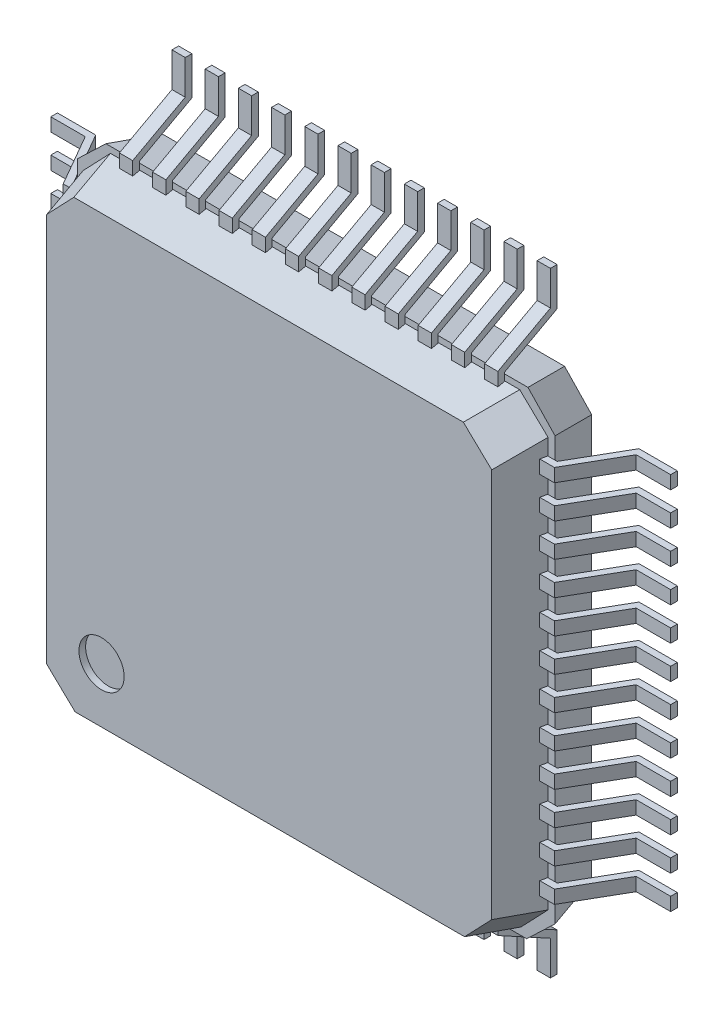
from build123d import *
from OCP.BRepFilletAPI import BRepFilletAPI_MakeChamfer

# Parameters (mm, degrees)
SKETCH1_W             = 7
SKETCH1_H             = 7
BOSS_EXTRUDE1_DEPTH   = 0.7
BOSS_EXTRUDE1_TAPER   = 12
CHAMFER1_SIZE         = 0.4
CHAMFER1_SIZE2        = 0.418480959
SKETCH2_W             = 7.192202475
SKETCH2_H             = 7.202004905
BOSS_EXTRUDE2_DEPTH   = 0.7
BOSS_EXTRUDE2_DRAFT   = -12
CHAMFER3_SIZE         = 0.4
CHAMFER3_SIZE2        = 0.418480959
EXTRUDE_THIN1_DEPTH   = 0.1
LPATTERN1_COUNT       = 7
LPATTERN1_PITCH       = 0.5
LPATTERN1_COL_COUNT   = 6
LPATTERN1_COL_PITCH   = 0.5
MIRROR2_COPY_1_DEPTH  = 0.1
MIRROR2_COPY_2_DEPTH  = 0.1
MIRROR2_COPY_3_DEPTH  = 0.1
MIRROR2_COPY_4_DEPTH  = 0.1
MIRROR2_COPY_5_DEPTH  = 0.1
MIRROR2_COPY_6_DEPTH  = 0.1
MIRROR2_COPY_7_DEPTH  = 0.1
MIRROR2_COPY_8_DEPTH  = 0.1
MIRROR2_COPY_9_DEPTH  = 0.1
MIRROR2_COPY_10_DEPTH = 0.1
MIRROR2_COPY_11_DEPTH = 0.1
EXTRUDE_THIN2_DEPTH   = 0.1
LPATTERN2_COUNT       = 7
LPATTERN2_PITCH       = 0.5
LPATTERN2_COL_COUNT   = 6
LPATTERN2_COL_PITCH   = 0.5
MIRROR3_COPY_1_DEPTH  = 0.1
MIRROR3_COPY_2_DEPTH  = 0.1
MIRROR3_COPY_3_DEPTH  = 0.1
MIRROR3_COPY_4_DEPTH  = 0.1
MIRROR3_COPY_5_DEPTH  = 0.1
MIRROR3_COPY_6_DEPTH  = 0.1
MIRROR3_COPY_7_DEPTH  = 0.1
MIRROR3_COPY_8_DEPTH  = 0.1
MIRROR3_COPY_9_DEPTH  = 0.1
MIRROR3_COPY_10_DEPTH = 0.1
MIRROR3_COPY_11_DEPTH = 0.1
SKETCH6_R             = 0.340417577
CUT_EXTRUDE2_DEPTH    = 0.1


with BuildPart() as part:
    # Sketch1 → Boss-Extrude1 (new body)
    with BuildSketch(Plane.XY):
        with Locations((3.5, 3.5)):
            Rectangle(SKETCH1_W, SKETCH1_H)
    extrude(amount=BOSS_EXTRUDE1_DEPTH, taper=BOSS_EXTRUDE1_TAPER)

    # Chamfer1: one chamfer whose edges measure the first distance from different faces: ONE call of the kernel's chamfer builder (chamfer() names one face for all edges)
    chamfer1_edges_1 = [part.edges().sort_by_distance(p)[0] for p in [
        (0.074394797, 6.925605203, 0.35),
    ]]
    chamfer1_side_1 = [part.faces().sort_by_distance(p)[0] for p in [
        (3.5, 6.926143754, 0.347466318),
    ]]
    chamfer1_edges_2 = [part.edges().sort_by_distance(p)[0] for p in [
        (6.925605203, 6.925605203, 0.35),
    ]]
    chamfer1_side_2 = [part.faces().sort_by_distance(p)[0] for p in [
        (6.926143754, 3.5, 0.347466318),
    ]]
    chamfer1_edges_3 = [part.edges().sort_by_distance(p)[0] for p in [
        (6.925605203, 0.074394797, 0.35),
    ]]
    chamfer1_side_3 = [part.faces().sort_by_distance(p)[0] for p in [
        (3.5, 0.073856246, 0.347466318),
    ]]
    chamfer1_edges_4 = [part.edges().sort_by_distance(p)[0] for p in [
        (0.074395259, 0.074395259, 0.350002173),
    ]]
    chamfer1_side_4 = [part.faces().sort_by_distance(p)[0] for p in [
        (0.073856246, 3.5, 0.347466318),
    ]]
    chamfer1 = BRepFilletAPI_MakeChamfer(part.part.solid().wrapped)
    for e in chamfer1_edges_1:
        chamfer1.Add(CHAMFER1_SIZE, CHAMFER1_SIZE2, e.wrapped, chamfer1_side_1[0].wrapped)  # the first distance lies on this face
    for e in chamfer1_edges_2:
        chamfer1.Add(CHAMFER1_SIZE, CHAMFER1_SIZE2, e.wrapped, chamfer1_side_2[0].wrapped)  # the first distance lies on this face
    for e in chamfer1_edges_3:
        chamfer1.Add(CHAMFER1_SIZE, CHAMFER1_SIZE2, e.wrapped, chamfer1_side_3[0].wrapped)  # the first distance lies on this face
    for e in chamfer1_edges_4:
        chamfer1.Add(CHAMFER1_SIZE, CHAMFER1_SIZE2, e.wrapped, chamfer1_side_4[0].wrapped)  # the first distance lies on this face
    add(Compound.cast(chamfer1.Shape()), mode=Mode.REPLACE)


with BuildPart() as boss_extrude2_tool:
    # Sketch2 → Boss-Extrude2 (with draft: the straight prism first)
    with BuildSketch(Plane.XY):
        with Locations((3.509438087, 3.490561914)):
            Rectangle(SKETCH2_W, SKETCH2_H)
    extrude(amount=-BOSS_EXTRUDE2_DEPTH)
    # Boss-Extrude2: the draft: its side faces are tilted about the plane it starts from
    boss_extrude2_sides = [boss_extrude2_tool.faces().sort_by_distance(p)[0] for p in [
        (3.509438087, -0.110440539, -0.35),
        (7.105539324, 3.490561913, -0.35),
        (3.509438087, 7.091564366, -0.35),
        (-0.086663151, 3.490561913, -0.35),
    ]]
    draft(boss_extrude2_sides, Plane.XY, BOSS_EXTRUDE2_DRAFT)


with BuildPart() as part_1:
    add(part.part)

    # Boss-Extrude2: add boss_extrude2_tool
    add(boss_extrude2_tool.part)

    # Chamfer3: one chamfer whose edges measure the first distance from different faces: ONE call of the kernel's chamfer builder (chamfer() names one face for all edges)
    chamfer3_edges_1 = [part_1.edges().sort_by_distance(p)[0] for p in [
        (7.031144528, 7.017169569, -0.35),
    ]]
    chamfer3_side_1 = [part_1.faces().sort_by_distance(p)[0] for p in [
        (3.509438087, 7.017693424, -0.347535458),
    ]]
    chamfer3_edges_2 = [part_1.edges().sort_by_distance(p)[0] for p in [
        (7.031144528, -0.036045743, -0.35),
    ]]
    chamfer3_side_2 = [part_1.faces().sort_by_distance(p)[0] for p in [
        (7.031667654, 3.490561913, -0.347538883),
    ]]
    chamfer3_edges_3 = [part_1.edges().sort_by_distance(p)[0] for p in [
        (-0.012268354, -0.036045743, -0.35),
    ]]
    chamfer3_side_3 = [part_1.faces().sort_by_distance(p)[0] for p in [
        (3.509438087, -0.036569597, -0.347535458),
    ]]
    chamfer3_edges_4 = [part_1.edges().sort_by_distance(p)[0] for p in [
        (-0.012268354, 7.017169569, -0.35),
    ]]
    chamfer3_side_4 = [part_1.faces().sort_by_distance(p)[0] for p in [
        (-0.01279148, 3.490561913, -0.347538883),
    ]]
    chamfer3 = BRepFilletAPI_MakeChamfer(part_1.part.solid().wrapped)
    for e in chamfer3_edges_1:
        chamfer3.Add(CHAMFER3_SIZE, CHAMFER3_SIZE2, e.wrapped, chamfer3_side_1[0].wrapped)  # the first distance lies on this face
    for e in chamfer3_edges_2:
        chamfer3.Add(CHAMFER3_SIZE, CHAMFER3_SIZE2, e.wrapped, chamfer3_side_2[0].wrapped)  # the first distance lies on this face
    for e in chamfer3_edges_3:
        chamfer3.Add(CHAMFER3_SIZE, CHAMFER3_SIZE2, e.wrapped, chamfer3_side_3[0].wrapped)  # the first distance lies on this face
    for e in chamfer3_edges_4:
        chamfer3.Add(CHAMFER3_SIZE, CHAMFER3_SIZE2, e.wrapped, chamfer3_side_4[0].wrapped)  # the first distance lies on this face
    add(Compound.cast(chamfer3.Shape()), mode=Mode.REPLACE)

    # Sketch3 → Extrude-Thin1 (add, symmetric)
    with BuildSketch(Plane(origin=(3.25, 0, 0), x_dir=(0, 0, -1), z_dir=(1, 0, 0))):
        Polygon((-0.006078163, 6.940862038), (-0.006078163, 7.119720469), (0.785126281, 7.550736247), (0.785126281, 8.128374183), (0.685126281, 8.128374183), (0.685126281, 7.610135819), (-0.106078163, 7.179120041), (-0.106078163, 6.940862038), align=None)
    extrude_thin1 = extrude(amount=EXTRUDE_THIN1_DEPTH, both=True)

    # LPattern1: Extrude-Thin1 ×7
    with Locations(*[(i * LPATTERN1_PITCH, 0, 0) for i in range(1, LPATTERN1_COUNT)]):
        add(extrude_thin1)

    # LPattern1 col: Extrude-Thin1 ×6
    with Locations(*[(-i * LPATTERN1_COL_PITCH, 0, 0) for i in range(1, LPATTERN1_COL_COUNT)]):
        add(extrude_thin1)

    # Mirror2: Extrude-Thin1 across plane
    add(extrude_thin1.mirror(Plane.ZX.offset(3.5)))

    # Mirror2 copy 1 sketch → Mirror2 copy 1 (add, symmetric)
    with BuildSketch(Plane(origin=(3.75, 7, 0), x_dir=(0, 0, -1), z_dir=(1, 0, 0))):
        Polygon((-0.006078163, -6.940862038), (-0.006078163, -7.119720469), (0.785126281, -7.550736247), (0.785126281, -8.128374183), (0.685126281, -8.128374183), (0.685126281, -7.610135819), (-0.106078163, -7.179120041), (-0.106078163, -6.940862038), align=None)
    extrude(amount=MIRROR2_COPY_1_DEPTH, both=True)

    # Mirror2 copy 2 sketch → Mirror2 copy 2 (add, symmetric)
    with BuildSketch(Plane(origin=(4.25, 7, 0), x_dir=(0, 0, -1), z_dir=(1, 0, 0))):
        Polygon((-0.006078163, -6.940862038), (-0.006078163, -7.119720469), (0.785126281, -7.550736247), (0.785126281, -8.128374183), (0.685126281, -8.128374183), (0.685126281, -7.610135819), (-0.106078163, -7.179120041), (-0.106078163, -6.940862038), align=None)
    extrude(amount=MIRROR2_COPY_2_DEPTH, both=True)

    # Mirror2 copy 3 sketch → Mirror2 copy 3 (add, symmetric)
    with BuildSketch(Plane(origin=(4.75, 7, 0), x_dir=(0, 0, -1), z_dir=(1, 0, 0))):
        Polygon((-0.006078163, -6.940862038), (-0.006078163, -7.119720469), (0.785126281, -7.550736247), (0.785126281, -8.128374183), (0.685126281, -8.128374183), (0.685126281, -7.610135819), (-0.106078163, -7.179120041), (-0.106078163, -6.940862038), align=None)
    extrude(amount=MIRROR2_COPY_3_DEPTH, both=True)

    # Mirror2 copy 4 sketch → Mirror2 copy 4 (add, symmetric)
    with BuildSketch(Plane(origin=(5.25, 7, 0), x_dir=(0, 0, -1), z_dir=(1, 0, 0))):
        Polygon((-0.006078163, -6.940862038), (-0.006078163, -7.119720469), (0.785126281, -7.550736247), (0.785126281, -8.128374183), (0.685126281, -8.128374183), (0.685126281, -7.610135819), (-0.106078163, -7.179120041), (-0.106078163, -6.940862038), align=None)
    extrude(amount=MIRROR2_COPY_4_DEPTH, both=True)

    # Mirror2 copy 5 sketch → Mirror2 copy 5 (add, symmetric)
    with BuildSketch(Plane(origin=(5.75, 7, 0), x_dir=(0, 0, -1), z_dir=(1, 0, 0))):
        Polygon((-0.006078163, -6.940862038), (-0.006078163, -7.119720469), (0.785126281, -7.550736247), (0.785126281, -8.128374183), (0.685126281, -8.128374183), (0.685126281, -7.610135819), (-0.106078163, -7.179120041), (-0.106078163, -6.940862038), align=None)
    extrude(amount=MIRROR2_COPY_5_DEPTH, both=True)

    # Mirror2 copy 6 sketch → Mirror2 copy 6 (add, symmetric)
    with BuildSketch(Plane(origin=(6.25, 7, 0), x_dir=(0, 0, -1), z_dir=(1, 0, 0))):
        Polygon((-0.006078163, -6.940862038), (-0.006078163, -7.119720469), (0.785126281, -7.550736247), (0.785126281, -8.128374183), (0.685126281, -8.128374183), (0.685126281, -7.610135819), (-0.106078163, -7.179120041), (-0.106078163, -6.940862038), align=None)
    extrude(amount=MIRROR2_COPY_6_DEPTH, both=True)

    # Mirror2 copy 7 sketch → Mirror2 copy 7 (add, symmetric)
    with BuildSketch(Plane(origin=(2.75, 7, 0), x_dir=(0, 0, -1), z_dir=(1, 0, 0))):
        Polygon((-0.006078163, -6.940862038), (-0.006078163, -7.119720469), (0.785126281, -7.550736247), (0.785126281, -8.128374183), (0.685126281, -8.128374183), (0.685126281, -7.610135819), (-0.106078163, -7.179120041), (-0.106078163, -6.940862038), align=None)
    extrude(amount=MIRROR2_COPY_7_DEPTH, both=True)

    # Mirror2 copy 8 sketch → Mirror2 copy 8 (add, symmetric)
    with BuildSketch(Plane(origin=(2.25, 7, 0), x_dir=(0, 0, -1), z_dir=(1, 0, 0))):
        Polygon((-0.006078163, -6.940862038), (-0.006078163, -7.119720469), (0.785126281, -7.550736247), (0.785126281, -8.128374183), (0.685126281, -8.128374183), (0.685126281, -7.610135819), (-0.106078163, -7.179120041), (-0.106078163, -6.940862038), align=None)
    extrude(amount=MIRROR2_COPY_8_DEPTH, both=True)

    # Mirror2 copy 9 sketch → Mirror2 copy 9 (add, symmetric)
    with BuildSketch(Plane(origin=(1.75, 7, 0), x_dir=(0, 0, -1), z_dir=(1, 0, 0))):
        Polygon((-0.006078163, -6.940862038), (-0.006078163, -7.119720469), (0.785126281, -7.550736247), (0.785126281, -8.128374183), (0.685126281, -8.128374183), (0.685126281, -7.610135819), (-0.106078163, -7.179120041), (-0.106078163, -6.940862038), align=None)
    extrude(amount=MIRROR2_COPY_9_DEPTH, both=True)

    # Mirror2 copy 10 sketch → Mirror2 copy 10 (add, symmetric)
    with BuildSketch(Plane(origin=(1.25, 7, 0), x_dir=(0, 0, -1), z_dir=(1, 0, 0))):
        Polygon((-0.006078163, -6.940862038), (-0.006078163, -7.119720469), (0.785126281, -7.550736247), (0.785126281, -8.128374183), (0.685126281, -8.128374183), (0.685126281, -7.610135819), (-0.106078163, -7.179120041), (-0.106078163, -6.940862038), align=None)
    extrude(amount=MIRROR2_COPY_10_DEPTH, both=True)

    # Mirror2 copy 11 sketch → Mirror2 copy 11 (add, symmetric)
    with BuildSketch(Plane(origin=(0.75, 7, 0), x_dir=(0, 0, -1), z_dir=(1, 0, 0))):
        Polygon((-0.006078163, -6.940862038), (-0.006078163, -7.119720469), (0.785126281, -7.550736247), (0.785126281, -8.128374183), (0.685126281, -8.128374183), (0.685126281, -7.610135819), (-0.106078163, -7.179120041), (-0.106078163, -6.940862038), align=None)
    extrude(amount=MIRROR2_COPY_11_DEPTH, both=True)

    # Sketch5 → Extrude-Thin2 (add, symmetric)
    with BuildSketch(Plane(origin=(0, 3.75, 0), x_dir=(1, 0, 0), z_dir=(0, 1, 0))):
        Polygon((0.038484728, -0.003747619), (-0.141163367, -0.003747619), (-0.591163367, 0.777980368), (-1.168011639, 0.777980368), (-1.168011639, 0.677980368), (-0.648983611, 0.677980368), (-0.198983611, -0.103747619), (0.038484728, -0.103747619), align=None)
    extrude_thin2 = extrude(amount=EXTRUDE_THIN2_DEPTH, both=True)

    # LPattern2: Extrude-Thin2 ×7
    with Locations(*[(0, -i * LPATTERN2_PITCH, 0) for i in range(1, LPATTERN2_COUNT)]):
        add(extrude_thin2)

    # LPattern2 col: Extrude-Thin2 ×6
    with Locations(*[(0, i * LPATTERN2_COL_PITCH, 0) for i in range(1, LPATTERN2_COL_COUNT)]):
        add(extrude_thin2)

    # Mirror3: Extrude-Thin2 across plane
    add(extrude_thin2.mirror(Plane(origin=(3.5, 0, 0), x_dir=(0, 0, 1), z_dir=(1, 0, 0))))

    # Mirror3 copy 1 sketch → Mirror3 copy 1 (add, symmetric)
    with BuildSketch(Plane(origin=(7, 3.25, 0), x_dir=(-1, 0, 0), z_dir=(0, 1, 0))):
        Polygon((0.038484728, 0.003747619), (-0.141163367, 0.003747619), (-0.591163367, -0.777980368), (-1.168011639, -0.777980368), (-1.168011639, -0.677980368), (-0.648983611, -0.677980368), (-0.198983611, 0.103747619), (0.038484728, 0.103747619), align=None)
    extrude(amount=MIRROR3_COPY_1_DEPTH, both=True)

    # Mirror3 copy 2 sketch → Mirror3 copy 2 (add, symmetric)
    with BuildSketch(Plane(origin=(7, 2.75, 0), x_dir=(-1, 0, 0), z_dir=(0, 1, 0))):
        Polygon((0.038484728, 0.003747619), (-0.141163367, 0.003747619), (-0.591163367, -0.777980368), (-1.168011639, -0.777980368), (-1.168011639, -0.677980368), (-0.648983611, -0.677980368), (-0.198983611, 0.103747619), (0.038484728, 0.103747619), align=None)
    extrude(amount=MIRROR3_COPY_2_DEPTH, both=True)

    # Mirror3 copy 3 sketch → Mirror3 copy 3 (add, symmetric)
    with BuildSketch(Plane(origin=(7, 2.25, 0), x_dir=(-1, 0, 0), z_dir=(0, 1, 0))):
        Polygon((0.038484728, 0.003747619), (-0.141163367, 0.003747619), (-0.591163367, -0.777980368), (-1.168011639, -0.777980368), (-1.168011639, -0.677980368), (-0.648983611, -0.677980368), (-0.198983611, 0.103747619), (0.038484728, 0.103747619), align=None)
    extrude(amount=MIRROR3_COPY_3_DEPTH, both=True)

    # Mirror3 copy 4 sketch → Mirror3 copy 4 (add, symmetric)
    with BuildSketch(Plane(origin=(7, 1.75, 0), x_dir=(-1, 0, 0), z_dir=(0, 1, 0))):
        Polygon((0.038484728, 0.003747619), (-0.141163367, 0.003747619), (-0.591163367, -0.777980368), (-1.168011639, -0.777980368), (-1.168011639, -0.677980368), (-0.648983611, -0.677980368), (-0.198983611, 0.103747619), (0.038484728, 0.103747619), align=None)
    extrude(amount=MIRROR3_COPY_4_DEPTH, both=True)

    # Mirror3 copy 5 sketch → Mirror3 copy 5 (add, symmetric)
    with BuildSketch(Plane(origin=(7, 1.25, 0), x_dir=(-1, 0, 0), z_dir=(0, 1, 0))):
        Polygon((0.038484728, 0.003747619), (-0.141163367, 0.003747619), (-0.591163367, -0.777980368), (-1.168011639, -0.777980368), (-1.168011639, -0.677980368), (-0.648983611, -0.677980368), (-0.198983611, 0.103747619), (0.038484728, 0.103747619), align=None)
    extrude(amount=MIRROR3_COPY_5_DEPTH, both=True)

    # Mirror3 copy 6 sketch → Mirror3 copy 6 (add, symmetric)
    with BuildSketch(Plane(origin=(7, 0.75, 0), x_dir=(-1, 0, 0), z_dir=(0, 1, 0))):
        Polygon((0.038484728, 0.003747619), (-0.141163367, 0.003747619), (-0.591163367, -0.777980368), (-1.168011639, -0.777980368), (-1.168011639, -0.677980368), (-0.648983611, -0.677980368), (-0.198983611, 0.103747619), (0.038484728, 0.103747619), align=None)
    extrude(amount=MIRROR3_COPY_6_DEPTH, both=True)

    # Mirror3 copy 7 sketch → Mirror3 copy 7 (add, symmetric)
    with BuildSketch(Plane(origin=(7, 4.25, 0), x_dir=(-1, 0, 0), z_dir=(0, 1, 0))):
        Polygon((0.038484728, 0.003747619), (-0.141163367, 0.003747619), (-0.591163367, -0.777980368), (-1.168011639, -0.777980368), (-1.168011639, -0.677980368), (-0.648983611, -0.677980368), (-0.198983611, 0.103747619), (0.038484728, 0.103747619), align=None)
    extrude(amount=MIRROR3_COPY_7_DEPTH, both=True)

    # Mirror3 copy 8 sketch → Mirror3 copy 8 (add, symmetric)
    with BuildSketch(Plane(origin=(7, 4.75, 0), x_dir=(-1, 0, 0), z_dir=(0, 1, 0))):
        Polygon((0.038484728, 0.003747619), (-0.141163367, 0.003747619), (-0.591163367, -0.777980368), (-1.168011639, -0.777980368), (-1.168011639, -0.677980368), (-0.648983611, -0.677980368), (-0.198983611, 0.103747619), (0.038484728, 0.103747619), align=None)
    extrude(amount=MIRROR3_COPY_8_DEPTH, both=True)

    # Mirror3 copy 9 sketch → Mirror3 copy 9 (add, symmetric)
    with BuildSketch(Plane(origin=(7, 5.25, 0), x_dir=(-1, 0, 0), z_dir=(0, 1, 0))):
        Polygon((0.038484728, 0.003747619), (-0.141163367, 0.003747619), (-0.591163367, -0.777980368), (-1.168011639, -0.777980368), (-1.168011639, -0.677980368), (-0.648983611, -0.677980368), (-0.198983611, 0.103747619), (0.038484728, 0.103747619), align=None)
    extrude(amount=MIRROR3_COPY_9_DEPTH, both=True)

    # Mirror3 copy 10 sketch → Mirror3 copy 10 (add, symmetric)
    with BuildSketch(Plane(origin=(7, 5.75, 0), x_dir=(-1, 0, 0), z_dir=(0, 1, 0))):
        Polygon((0.038484728, 0.003747619), (-0.141163367, 0.003747619), (-0.591163367, -0.777980368), (-1.168011639, -0.777980368), (-1.168011639, -0.677980368), (-0.648983611, -0.677980368), (-0.198983611, 0.103747619), (0.038484728, 0.103747619), align=None)
    extrude(amount=MIRROR3_COPY_10_DEPTH, both=True)

    # Mirror3 copy 11 sketch → Mirror3 copy 11 (add, symmetric)
    with BuildSketch(Plane(origin=(7, 6.25, 0), x_dir=(-1, 0, 0), z_dir=(0, 1, 0))):
        Polygon((0.038484728, 0.003747619), (-0.141163367, 0.003747619), (-0.591163367, -0.777980368), (-1.168011639, -0.777980368), (-1.168011639, -0.677980368), (-0.648983611, -0.677980368), (-0.198983611, 0.103747619), (0.038484728, 0.103747619), align=None)
    extrude(amount=MIRROR3_COPY_11_DEPTH, both=True)

    # Sketch6 → Cut-Extrude2 (cut)
    with BuildSketch(Plane.XY.offset(0.7)):
        with Locations((0.974702048, 0.975812186)):
            Circle(SKETCH6_R)
    extrude(amount=-CUT_EXTRUDE2_DEPTH, mode=Mode.SUBTRACT)


solid = part_1.part
